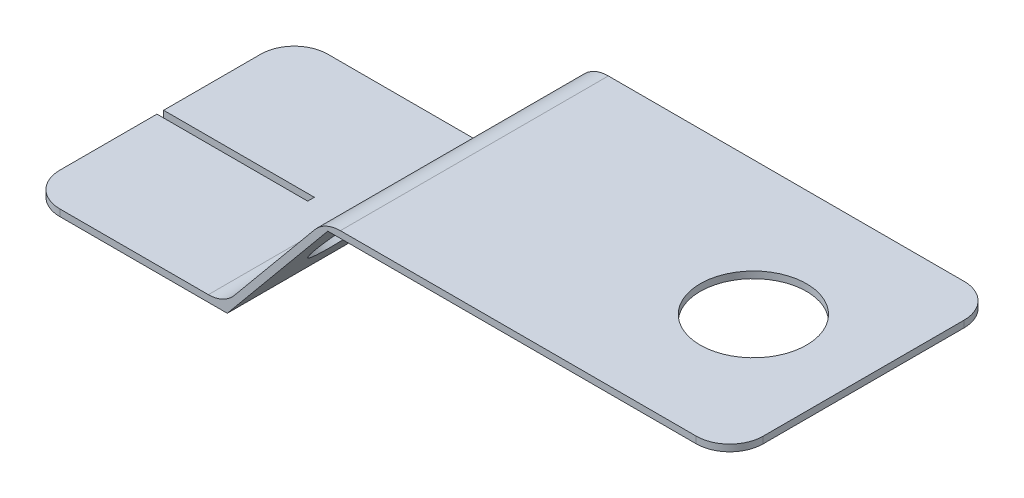
from build123d import *

# Parameters (mm, degrees)
BOSS_EXTRUDE1_DEPTH = 4
SKETCH2_R           = 1.5875
CUT_EXTRUDE1_DEPTH  = 10
FILLET1_R           = 1
SKETCH3_W           = 4.5
SKETCH3_H           = 0.2
CUT_EXTRUDE2_DEPTH  = 10
FILLET2_R           = 1
SKETCH4_R           = 1.190625
CUT_EXTRUDE3_DEPTH  = 10


with BuildPart() as part:
    # Sketch1 → Boss-Extrude1 (new body, symmetric)
    with BuildSketch(Plane.XY):
        Polygon((0, 0), (6, 0), (9, 3.625), (21, 3.625), (21, 3.825), (8.905909928, 3.825), (5.905909928, 0.2), (0, 0.2), align=None)
    extrude(amount=BOSS_EXTRUDE1_DEPTH, both=True)

    # Sketch2 → Cut-Extrude1 (cut)
    with BuildSketch(Plane(origin=(0, 3.825, 0), x_dir=(1, 0, 0), z_dir=(0, 1, 0))):
        with Locations((17.705909928, 0)):
            Circle(SKETCH2_R)
    extrude(amount=-CUT_EXTRUDE1_DEPTH, mode=Mode.SUBTRACT)

    # Fillet1
    fillet1_edges = [part.edges().sort_by_distance(p)[0] for p in [
        (0, 0.1, -4),
        (21, 3.725, 4),
        (0, 0.1, 4),
        (21, 3.725, -4),
    ]]
    fillet(fillet1_edges, radius=FILLET1_R)

    # Sketch3 → Cut-Extrude2 (cut)
    with BuildSketch(Plane(origin=(0, 0.2, 0), x_dir=(1, 0, 0), z_dir=(0, 1, 0))):
        with Locations((2.25, 0)):
            Rectangle(SKETCH3_W, SKETCH3_H)
    extrude(amount=-CUT_EXTRUDE2_DEPTH, mode=Mode.SUBTRACT)

    # Fillet2
    fillet2_edges = [part.edges().sort_by_distance(p)[0] for p in [
        (5.905909928, 0.2, 0),
        (8.905909928, 3.825, 0),
    ]]
    fillet(fillet2_edges, radius=FILLET2_R)

    # Sketch4 → Cut-Extrude3 (cut)
    with BuildSketch(Plane(origin=(3.406965596, -2.819557735, 0), x_dir=(0, 0, 1), z_dir=(-0.770394321, 0.637567714, 0))):
        with Locations((-1.75, 6.272187634)):
            Circle(SKETCH4_R)
    cut_extrude3 = extrude(amount=-CUT_EXTRUDE3_DEPTH, mode=Mode.SUBTRACT)

    # Mirror1: Cut-Extrude3 across plane
    add(cut_extrude3.mirror(Plane.XY), mode=Mode.SUBTRACT)


solid = part.part
